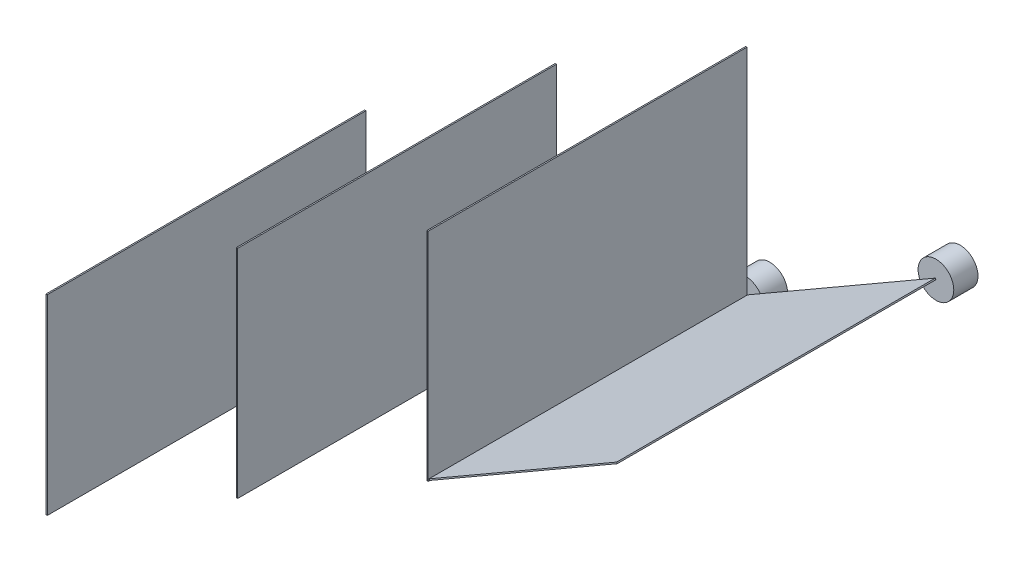
from build123d import *

# Parameters (mm, degrees)
EXTRUDE_2_DEPTH   = 250
SKETCH_1_W        = 1
SKETCH_1_H        = 170
EXTRUDE_2_2_DEPTH = 250
EXTRUDE_2_3_DEPTH = 250
SKETCH_1_H_2      = 150
EXTRUDE_2_4_DEPTH = 250
SKETCH_2_R        = 14
EXTRUDE_3_DEPTH   = 19


with BuildPart() as part:
    # 草图1 → 凸台-拉伸2 (new body)
    with BuildSketch(Plane.XY):
        Polygon((0, 0), (147.224318643, 85), (146.724318643, 85.866025404), (-0.5, 0.866025404), align=None)
    extrude(amount=EXTRUDE_2_DEPTH)



with BuildPart() as body_2:
    # 草图1 → Extrude 2 2 (new body)
    with BuildSketch(Plane.XY):
        with Locations((-1.665063509, 83.75)):
            Rectangle(SKETCH_1_W, SKETCH_1_H)
    extrude(amount=EXTRUDE_2_2_DEPTH)


with BuildPart() as body_3:
    # 草图1 → Extrude 2 3 (new body)
    with BuildSketch(Plane.XY):
        with Locations((-151.054445662, -2.5)):
            Rectangle(SKETCH_1_W, SKETCH_1_H)
    extrude(amount=EXTRUDE_2_3_DEPTH)


with BuildPart() as body_4:
    # 草图1 → Extrude 2 4 (new body)
    with BuildSketch(Plane.XY):
        with Locations((-300.443827815, -98.75)):
            Rectangle(SKETCH_1_W, SKETCH_1_H_2)
    extrude(amount=EXTRUDE_2_4_DEPTH)


with BuildPart() as part_1:
    add(part.part)

    add(body_2.part)  # 凸台-拉伸3 merges body 2

    add(body_3.part)  # 凸台-拉伸3 merges body 3

    add(body_4.part)  # 凸台-拉伸3 merges body 4
    # 草图2 → 凸台-拉伸3 (add)
    with BuildSketch(Plane.XY):
        with Locations((147.224318643, 85)):
            Circle(SKETCH_2_R)
        with Locations((-2.165063509, -1.25)):
            Circle(SKETCH_2_R)
        with Locations((-151.554445662, -87.5)):
            Circle(SKETCH_2_R)
        with Locations((-300.943827815, -173.75)):
            Circle(SKETCH_2_R)
    extrude(amount=-EXTRUDE_3_DEPTH)


solid = part_1.part
